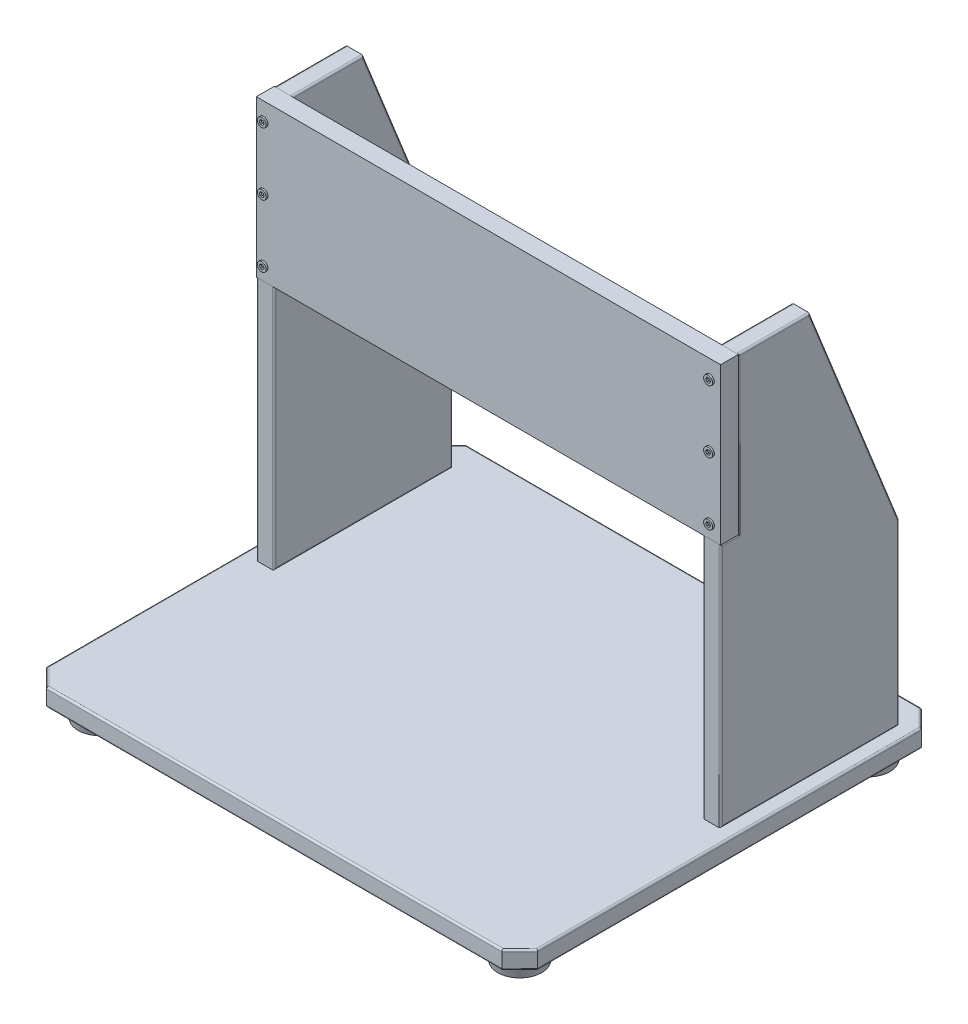
from build123d import *

# Parameters (mm, degrees)
SKETCH1_W           = 550
SKETCH1_H           = 470
BOSS_EXTRUDE1_DEPTH = 20
CHAMFER1_SIZE       = 20
SKETCH2_W           = 20
SKETCH2_H           = 200
BOSS_EXTRUDE2_DEPTH = 450
SKETCH3_W           = 20
SKETCH3_H           = 175
CUT_EXTRUDE1_DEPTH  = 515
SKETCH4_W           = 520
SKETCH4_H           = 175
BOSS_EXTRUDE3_DEPTH = 20
SKETCH5_R           = 30
BOSS_EXTRUDE4_DEPTH = 20
BOSS_EXTRUDE4_TAPER = 15
FILLET1_R           = 2
FILLET2_R           = 2
FILLET3_R           = 2
SKETCH6_R           = 5
BOSS_EXTRUDE5_DEPTH = 2
LPATTERN3_COUNT     = 2
LPATTERN3_PITCH     = 500
LPATTERN3_2_COUNT   = 3
LPATTERN3_2_PITCH   = 70


with BuildPart() as part:
    # Sketch1 → Boss-Extrude1 (new body)
    with BuildSketch(Plane(origin=(0, 0, 0), x_dir=(1, 0, 0), z_dir=(0, 1, 0))):
        Rectangle(SKETCH1_W, SKETCH1_H)
    extrude(amount=BOSS_EXTRUDE1_DEPTH)

    # Chamfer1
    chamfer1_edges = [part.edges().sort_by_distance(p)[0] for p in [
        (275, 10, 235),
        (-275, 10, 235),
        (-275, 10, -235),
        (275, 10, -235),
    ]]
    chamfer(chamfer1_edges, length=CHAMFER1_SIZE)

    # Fillet1
    fillet1_edges = [part.edges().sort_by_distance(p)[0] for p in [
        (0, 0, -235),
        (0, 20, -235),
        (275, 0, 0),
        (0, 0, 235),
        (-275, 0, 0),
        (-265, 0, 225),
        (265, 0, 225),
        (-265, 0, -225),
        (265, 0, -225),
        (275, 20, 0),
        (-275, 20, 0),
        (0, 20, 235),
        (-265, 20, 225),
        (265, 20, 225),
        (-265, 20, -225),
        (265, 20, -225),
    ]]
    fillet(fillet1_edges, radius=FILLET1_R)


with BuildPart() as body_2:
    # Sketch2 → Boss-Extrude2 (new body)
    with BuildSketch(Plane(origin=(0, 20, 0), x_dir=(1, 0, 0), z_dir=(0, 1, 0))):
        with Locations((-250, 105)):
            Rectangle(SKETCH2_W, SKETCH2_H)
    extrude(amount=BOSS_EXTRUDE2_DEPTH)

    # Sketch3 → Cut-Extrude1 (cut)
    with BuildSketch(Plane.ZY.offset(260)):
        Polygon((-205, 470), (-205, 220), (-105, 470), align=None)
        with Locations((-15, 382.5)):
            Rectangle(SKETCH3_W, SKETCH3_H)
    extrude(amount=-CUT_EXTRUDE1_DEPTH, mode=Mode.SUBTRACT)


with BuildPart() as body_3:
    # Mirror1: mirrored copy
    add(body_2.part.mirror(Plane(origin=(0, 0, 0), x_dir=(0, 0, 1), z_dir=(1, 0, 0))))

    # Fillet3
    fillet3_edges = [body_3.edges().sort_by_distance(p)[0] for p in [
        (260, 470, -65),
        (240, 470, -65),
        (260, 120, -205),
        (240, 120, -205),
        (240, 157.5, -5),
        (240, 295, -15),
        (260, 157.5, -5),
        (240, 345, -155),
        (260, 345, -155),
        (240, 382.5, -25),
        (260, 382.5, -25),
        (260, 295, -15),
        (240, 20, -105),
        (260, 20, -105),
    ]]
    fillet(fillet3_edges, radius=FILLET3_R)


with BuildPart() as body_4:
    # Sketch4 → Boss-Extrude3 (new body)
    with BuildSketch(Plane.XY.offset(-25)):
        with Locations((0, 382.5)):
            Rectangle(SKETCH4_W, SKETCH4_H)
    extrude(amount=BOSS_EXTRUDE3_DEPTH)


with BuildPart() as body_5:
    # Sketch5 → Boss-Extrude4 (new body)
    with BuildSketch(Plane.XZ):
        with Locations((-235, 195)):
            Circle(SKETCH5_R)
    extrude(amount=BOSS_EXTRUDE4_DEPTH, taper=BOSS_EXTRUDE4_TAPER)


with BuildPart() as body_6:
    # Mirror2: mirrored copy
    add(body_5.part.mirror(Plane(origin=(0, 0, 0), x_dir=(0, 0, 1), z_dir=(1, 0, 0))))


with BuildPart() as body_7:
    # Mirror3: mirrored copy
    add(body_5.part.mirror(Plane.XY))


with BuildPart() as body_8:
    # Mirror3 2: mirrored copy
    add(body_6.part.mirror(Plane.XY))


with BuildPart() as body_2_1:
    add(body_2.part)

    # Fillet2
    fillet2_edges = [body_2_1.edges().sort_by_distance(p)[0] for p in [
        (-260, 470, -65),
        (-240, 470, -65),
        (-260, 120, -205),
        (-240, 120, -205),
        (-240, 157.5, -5),
        (-240, 295, -15),
        (-260, 157.5, -5),
        (-240, 345, -155),
        (-260, 345, -155),
        (-240, 382.5, -25),
        (-260, 382.5, -25),
        (-260, 295, -15),
        (-240, 20, -105),
        (-260, 20, -105),
    ]]
    fillet(fillet2_edges, radius=FILLET2_R)


with BuildPart() as body_9:
    # Sketch6 → Boss-Extrude5 (new body)
    with BuildSketch(Plane.XY.offset(-5)):
        with Locations((-252, 450)):
            Circle(SKETCH6_R)
        Polygon((-249.230457071, 450), (-250.615228536, 452.398494533), (-253.384771464, 452.398494533), (-254.769542929, 450), (-253.384771464, 447.601505467), (-250.615228536, 447.601505467), align=None, mode=Mode.SUBTRACT)
    extrude(amount=BOSS_EXTRUDE5_DEPTH)


with BuildPart() as lpattern3_1:
    # LPattern3: pattern copy
    add(body_9.part.moved(Location(Vector(1, 0, 0) * (1 * LPATTERN3_PITCH))))


with BuildPart() as lpattern3_2_1:
    # LPattern3 2: pattern copy
    add(body_9.part.moved(Location(Vector(0, -1, 0) * (1 * LPATTERN3_2_PITCH))))


with BuildPart() as lpattern3_2_2:
    # LPattern3 2: pattern copy
    add(body_9.part.moved(Location(Vector(0, -1, 0) * (2 * LPATTERN3_2_PITCH))))


with BuildPart() as lpattern3_2_3:
    # LPattern3 2: pattern copy
    add(lpattern3_1.part.moved(Location(Vector(0, -1, 0) * (1 * LPATTERN3_2_PITCH))))


with BuildPart() as lpattern3_2_4:
    # LPattern3 2: pattern copy
    add(lpattern3_1.part.moved(Location(Vector(0, -1, 0) * (2 * LPATTERN3_2_PITCH))))


solid = Compound([part.part, body_3.part, body_4.part, body_5.part, body_6.part, body_7.part, body_8.part, body_2_1.part, body_9.part, lpattern3_1.part, lpattern3_2_1.part, lpattern3_2_2.part, lpattern3_2_3.part, lpattern3_2_4.part])
